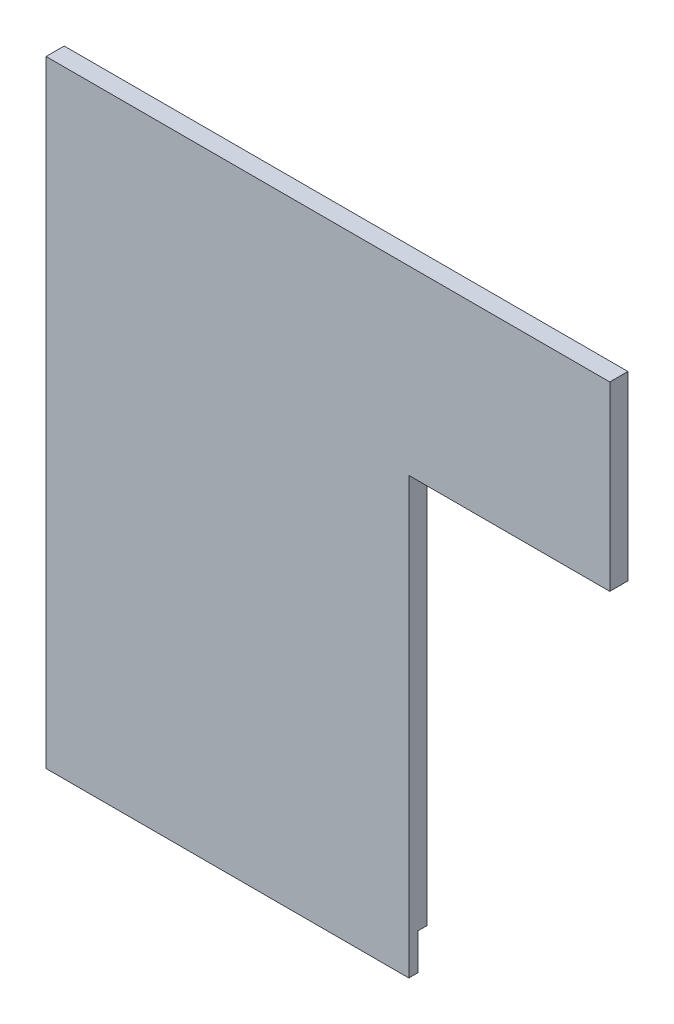
from build123d import *

# Parameters (mm, degrees)
BOSS_EXTRUDE1_DEPTH = 3.175
SKETCH3_W           = 63.5
SKETCH3_H           = 6.35
CUT_EXTRUDE2_DEPTH  = 1.5875


with BuildPart() as part:
    # Sketch1 → Boss-Extrude1 (new body)
    with BuildSketch(Plane.XY):
        Polygon((0, 0), (63.5, 0), (63.5, 76.2), (98.679, 76.2), (98.679, 107.95), (63.5, 107.95), (0, 107.95), align=None)
    extrude(amount=BOSS_EXTRUDE1_DEPTH)

    # Sketch3 → Cut-Extrude2 (cut)
    with BuildSketch(Plane(origin=(0, 0, 0), x_dir=(-1, 0, 0), z_dir=(0, 0, -1))):
        with Locations((-31.75, 3.175)):
            Rectangle(SKETCH3_W, SKETCH3_H)
    extrude(amount=-CUT_EXTRUDE2_DEPTH, mode=Mode.SUBTRACT)


solid = part.part
